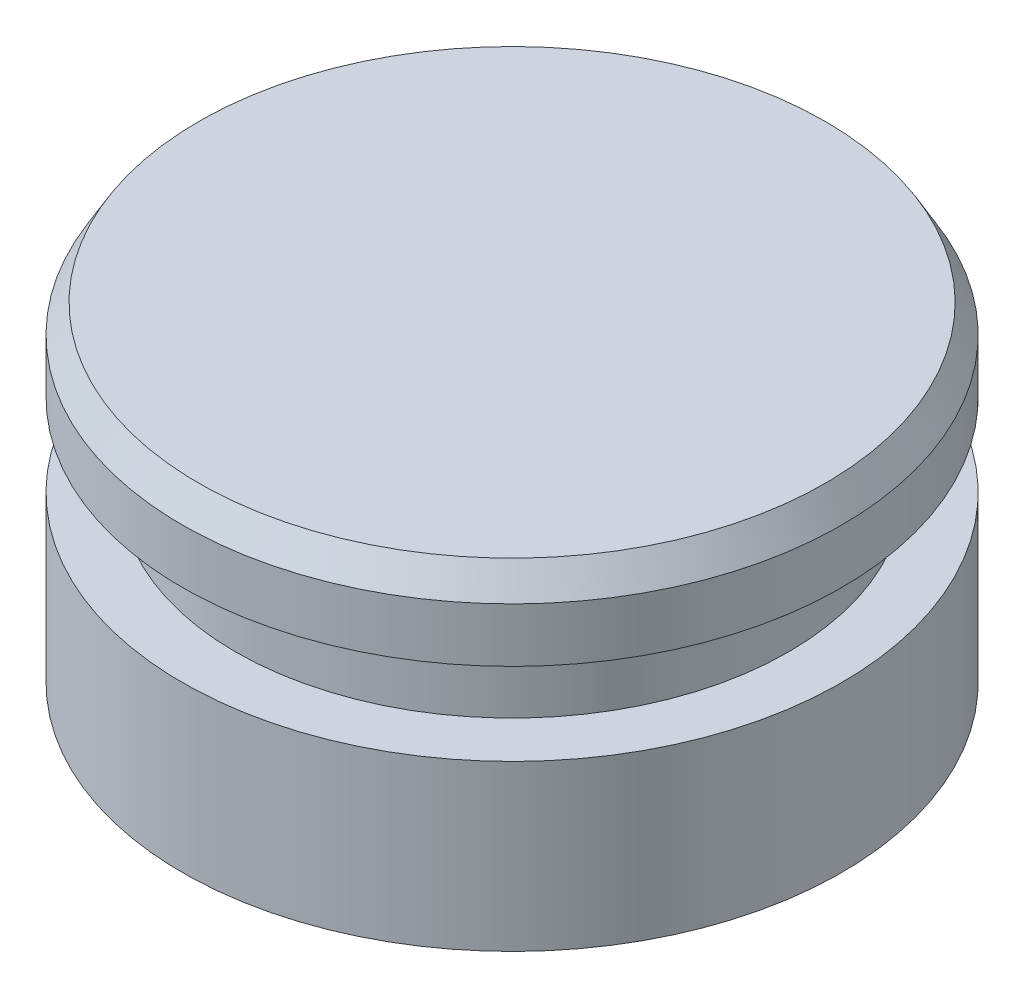
from build123d import *

# Parameters (mm, degrees)
CHAMFER1_SIZE  = 0.47037037
CHAMFER1_SIZE2 = 0.81470538


with BuildPart() as part:
    # Sketch1 → Revolve1 (revolve)
    with BuildSketch(Plane.XY):
        Polygon((0, 0), (-9.5377, 0), (-9.5377, 4.7625), (-8.001, 4.7625), (-8.001, 7.14375), (-9.5377, 7.14375), (-9.5377, 9.525), (0, 9.525), align=None)
    revolve(axis=Axis((0, 0, 0), (0, 1, 0)))

    # Chamfer1
    chamfer1_edges = [part.edges().sort_by_distance(p)[0] for p in [
        (9.5377, 9.525, 0),
    ]]
    chamfer1_side = [part.faces().sort_by_distance(p)[0] for p in [
        (0, 9.525, 0),
    ]]
    chamfer(chamfer1_edges, length=CHAMFER1_SIZE, length2=CHAMFER1_SIZE2, reference=chamfer1_side[0])


solid = part.part
